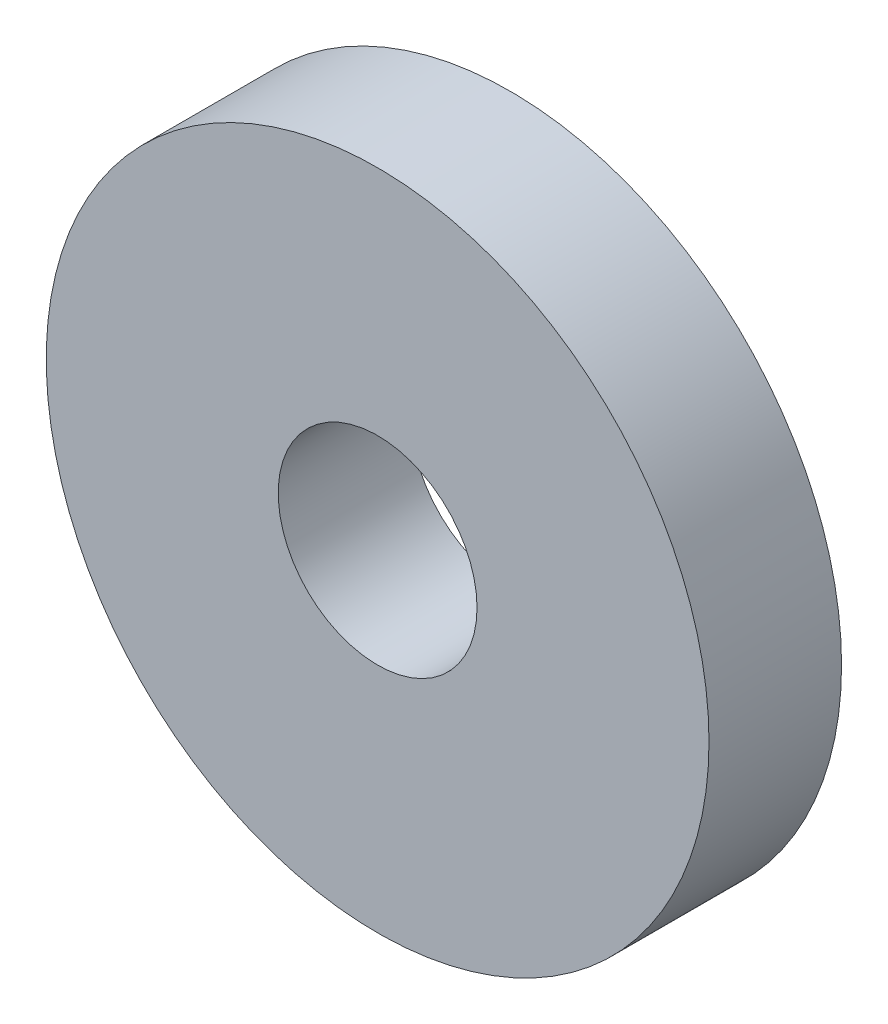
from build123d import *

# Parameters (mm, degrees)
SKETCH1_R           = 7.5
SKETCH1_R_2         = 2.25
BOSS_EXTRUDE1_DEPTH = 3


with BuildPart() as part:
    # Sketch1 → Boss-Extrude1 (new body)
    with BuildSketch(Plane.XY):
        Circle(SKETCH1_R)
        Circle(SKETCH1_R_2, mode=Mode.SUBTRACT)
    extrude(amount=BOSS_EXTRUDE1_DEPTH)


solid = part.part
